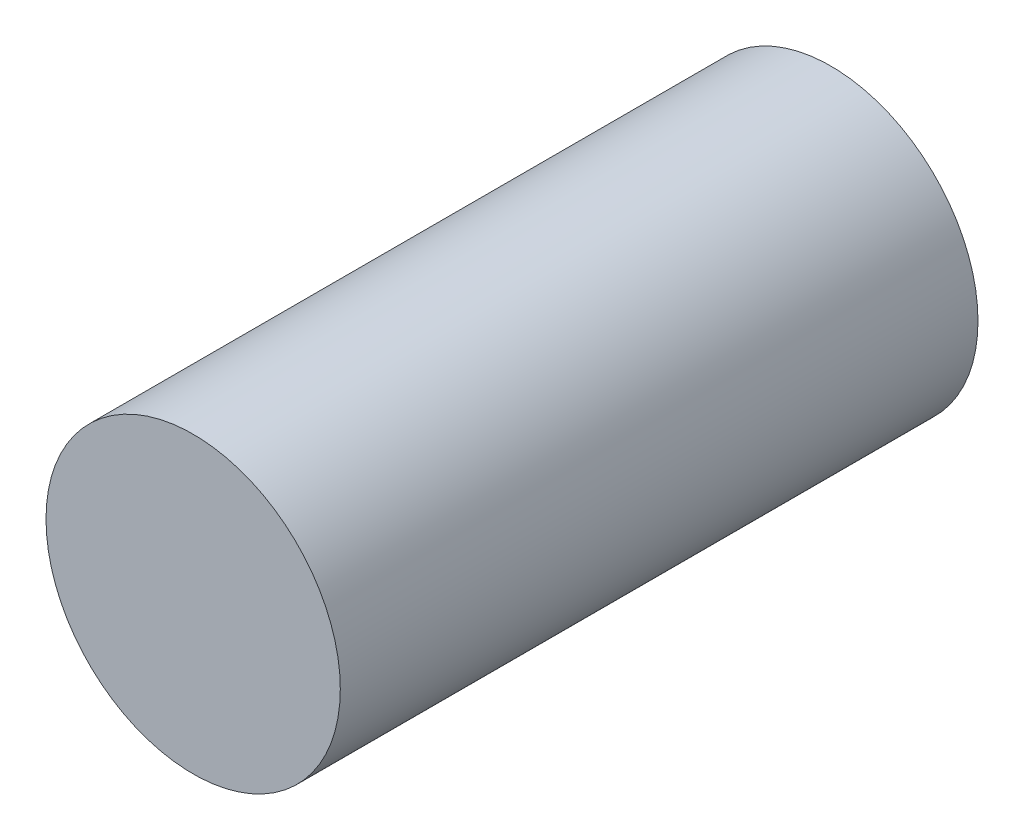
from build123d import *

# Parameters (mm, degrees)
SKETCH2_R           = 0.3
BOSS_EXTRUDE2_DEPTH = 1.3


with BuildPart() as part:
    # Sketch2 → Boss-Extrude2 (new body)
    with BuildSketch(Plane.XY):
        Circle(SKETCH2_R)
    extrude(amount=BOSS_EXTRUDE2_DEPTH)


solid = part.part
